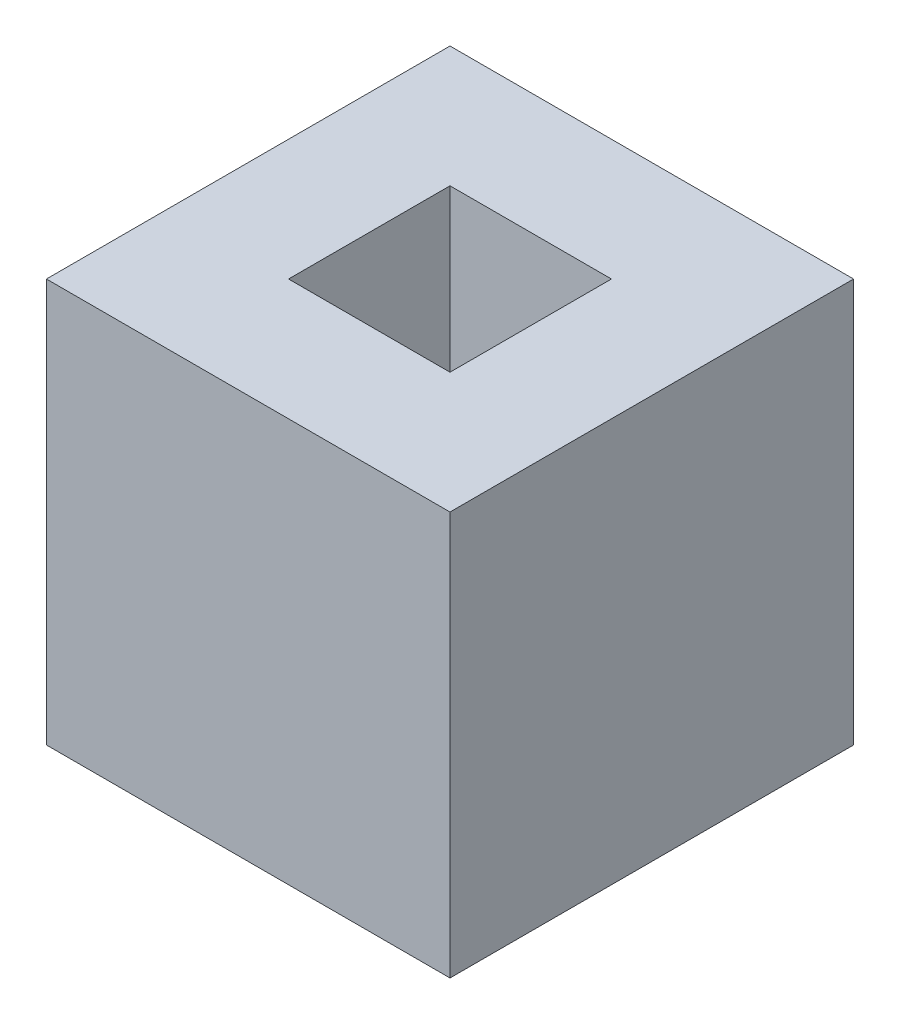
from build123d import *

# Parameters (mm, degrees)
SKETCH1_W           = 10
SKETCH1_H           = 10
BOSS_EXTRUDE1_DEPTH = 10
SKETCH2_W           = 4
SKETCH2_H           = 4
CUT_EXTRUDE1_DEPTH  = 11


with BuildPart() as part:
    # Sketch1 → Boss-Extrude1 (new body)
    with BuildSketch(Plane(origin=(0, 0, 0), x_dir=(1, 0, 0), z_dir=(0, 1, 0))):
        with Locations((5, 5)):
            Rectangle(SKETCH1_W, SKETCH1_H)
    extrude(amount=BOSS_EXTRUDE1_DEPTH)

    # Sketch2 → Cut-Extrude1 (cut, through all)
    with BuildSketch(Plane(origin=(0, 10, 0), x_dir=(1, 0, 0), z_dir=(0, 1, 0))):
        with Locations((5, 5)):
            Rectangle(SKETCH2_W, SKETCH2_H)
    extrude(amount=-CUT_EXTRUDE1_DEPTH, mode=Mode.SUBTRACT)


solid = part.part
